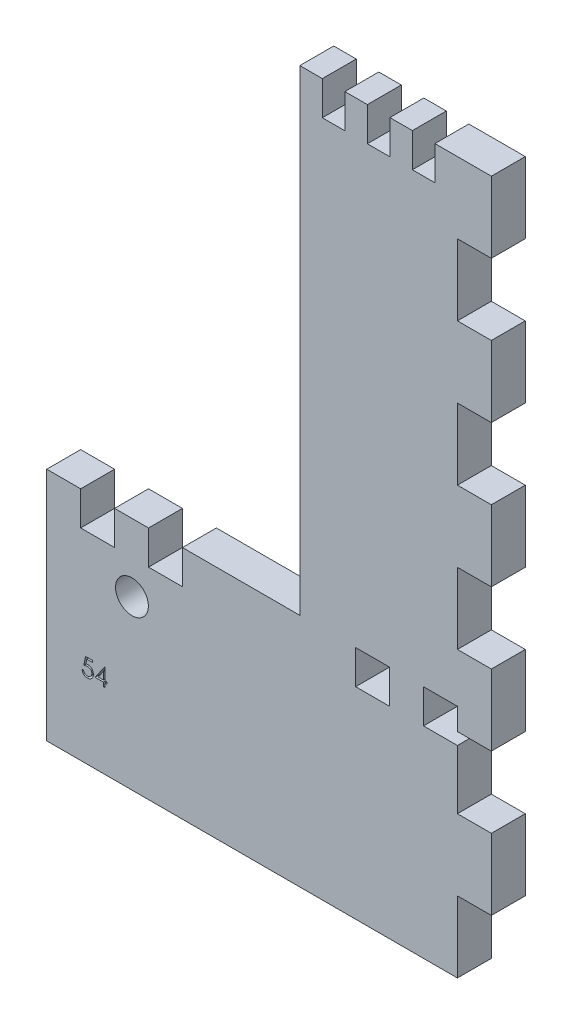
from build123d import *

# Parameters (mm, degrees)
SKETCH6_R           = 3
SKETCH6_W           = 6.2
SKETCH6_H           = 6.2
BOSS_EXTRUDE4_DEPTH = 6.2
CUT_EXTRUDE3_DEPTH  = 1


with BuildPart() as part:
    # Sketch6 → Boss-Extrude4 (new body)
    with BuildSketch(Plane.XY):
        Polygon((157.908027241, 124.653899243), (153.794027241, 124.653899243), (153.794027241, 37.653899243), (132.344027241, 37.653899243), (132.344027241, 31.453899243), (126.144027241, 31.453899243), (126.144027241, 37.653899243), (119.944027241, 37.653899243), (119.944027241, 31.453899243), (113.744027241, 31.453899243), (113.744027241, 37.653899243), (107.544027241, 37.653899243), (107.544027241, -5.346100757), (182.594027241, -5.346100757), (182.594027241, 7.653899243), (188.794027241, 7.653899243), (188.794027241, 20.653899243), (182.594027241, 20.653899243), (182.594027241, 31.453899243), (176.394027241, 31.453899243), (176.394027241, 37.653899243), (182.594027241, 37.653899243), (182.594027241, 33.653899243), (188.794027241, 33.653899243), (188.794027241, 46.653899243), (182.594027241, 46.653899243), (182.594027241, 59.653899243), (188.794027241, 59.653899243), (188.794027241, 72.653899243), (182.594027241, 72.653899243), (182.594027241, 85.653899243), (188.794027241, 85.653899243), (188.794027241, 98.653899243), (182.594027241, 98.653899243), (182.594027241, 111.653899243), (188.794027241, 111.653899243), (188.794027241, 124.653899243), (178.478027241, 124.653899243), (178.478027241, 118.453899243), (174.364027241, 118.453899243), (174.364027241, 124.653899243), (170.250027241, 124.653899243), (170.250027241, 118.453899243), (166.136027241, 118.453899243), (166.136027241, 124.653899243), (162.022027241, 124.653899243), (162.022027241, 118.453899243), (157.908027241, 118.453899243), align=None)
        with Locations((123.115137004, 25.259504391)):
            Circle(SKETCH6_R, mode=Mode.SUBTRACT)
        with Locations((167.094027241, 34.553899243)):
            Rectangle(SKETCH6_W, SKETCH6_H, mode=Mode.SUBTRACT)
    extrude(amount=BOSS_EXTRUDE4_DEPTH)

    # Sketch7 → Cut-Extrude3 (cut)
    with BuildSketch(Plane.XY.offset(6.2)):
        with BuildLine():
            Line((115.946331614, 11.576783669), (115.946331614, 11.251142644))
            Line((115.946331614, 11.251142644), (114.866373682, 11.251142644))
            Line((114.866373682, 11.251142644), (114.69528494, 10.416051498))
            add(Edge.make_bspline(
                [(114.69528494, 10.416051498), (114.728899911, 10.425331816), (114.794023603, 10.443310964), (114.890144334, 10.463273342), (114.981395832, 10.475306994), (115.040609919, 10.476950112), (115.069263305, 10.477745208)],
                knots=[0, 0, 0, 0, 0.000104595, 0.000202637, 0.000294305, 0.000380252, 0.000380252, 0.000380252, 0.000380252], degree=3))
            add(Edge.make_bspline(
                [(115.069263305, 10.477745208), (115.10471784, 10.476977823), (115.174430315, 10.475468954), (115.276428503, 10.460980204), (115.37379477, 10.43817471), (115.466325492, 10.40631538), (115.554191848, 10.365575836), (115.636585422, 10.314685176), (115.714742957, 10.255237083), (115.78726231, 10.186888393), (115.853052218, 10.111666641), (115.910897081, 10.030787715), (115.960030287, 9.945037622), (115.999546115, 9.853597069), (116.031100475, 9.75747698), (116.052102642, 9.655665995), (116.0660878, 9.549123772), (116.06765025, 9.476276054), (116.068446999, 9.439128421)],
                knots=[0, 0, 0, 0, 0.000106308, 0.000209029, 0.000308378, 0.000405929, 0.000502102, 0.000598312, 0.00069588, 0.000796219, 0.000896736, 0.000995218, 0.001094066, 0.001192613, 0.001293582, 0.001396995, 0.001504047, 0.001615439, 0.001615439, 0.001615439, 0.001615439], degree=3))
            add(Edge.make_bspline(
                [(116.068446999, 9.439128421), (116.067843681, 9.413254692), (116.066645197, 9.361856897), (116.060550479, 9.285526086), (116.048815936, 9.21081123), (116.033060929, 9.137702418), (116.012611736, 9.066338059), (115.987856666, 8.996513887), (115.957561698, 8.928664494), (115.924331807, 8.862147885), (115.886915359, 8.798467811), (115.845387713, 8.738914802), (115.801513304, 8.682595489), (115.754304332, 8.630113888), (115.703322001, 8.581814865), (115.649183746, 8.537411781), (115.592321565, 8.496153717), (115.531855738, 8.459715426), (115.469133628, 8.426184744), (115.40324946, 8.398676964), (115.335702967, 8.374083842), (115.265521973, 8.354480913), (115.192865443, 8.339120668), (115.117613611, 8.32868798), (115.040161146, 8.321089354), (114.987660242, 8.320613688), (114.961140308, 8.320373413)],
                knots=[0, 0, 0, 0, 7.7636e-05, 0.000154223, 0.000229512, 0.000304362, 0.000378447, 0.000452077, 0.000526407, 0.000601214, 0.00067506, 0.000747747, 0.00081887, 0.000889121, 0.000959302, 0.001029336, 0.001099058, 0.00116985, 0.001240974, 0.00131221, 0.00138383, 0.001456517, 0.001530612, 0.001606437, 0.001684346, 0.001763871, 0.001763871, 0.001763871, 0.001763871], degree=3))
            add(Edge.make_bspline(
                [(114.961140308, 8.320373413), (114.929504444, 8.321000102), (114.867264619, 8.322233038), (114.776078105, 8.335131235), (114.688344141, 8.353604216), (114.604768978, 8.38139569), (114.524603617, 8.41621845), (114.448927295, 8.460229548), (114.375806341, 8.51010345), (114.308213279, 8.568959198), (114.245478804, 8.633289853), (114.189320757, 8.703101427), (114.139306727, 8.777241707), (114.096237628, 8.856070747), (114.059500137, 8.939381414), (114.030639398, 9.02748585), (114.007345461, 9.119923711), (113.997490787, 9.183562967), (113.99248546, 9.215886233)],
                knots=[0, 0, 0, 0, 9.4843e-05, 0.000186593, 0.000275792, 0.000363484, 0.000450342, 0.000537514, 0.000625728, 0.000715478, 0.000805885, 0.000894984, 0.00098389, 0.001073836, 0.001164117, 0.001256635, 0.001351658, 0.001449737, 0.001449737, 0.001449737, 0.001449737], degree=3))
            Line((113.99248546, 9.215886233), (114.277421358, 9.215886233))
            add(Edge.make_bspline(
                [(114.277421358, 9.215886233), (114.284432264, 9.185609023), (114.297907613, 9.127414543), (114.327485686, 9.045652541), (114.36364973, 8.972791531), (114.406652246, 8.907867695), (114.457951202, 8.851253818), (114.516488613, 8.800801198), (114.582118333, 8.755285188), (114.655046477, 8.717345963), (114.731984056, 8.684989308), (114.812508596, 8.663443128), (114.894427539, 8.648293032), (114.949834347, 8.646776506), (114.977676767, 8.646014439)],
                knots=[0, 0, 0, 0, 9.3172e-05, 0.000179081, 0.000260145, 0.000336703, 0.000411917, 0.000488562, 0.000568128, 0.000650923, 0.00073478, 0.000817953, 0.000900557, 0.000983994, 0.000983994, 0.000983994, 0.000983994], degree=3))
            add(Edge.make_bspline(
                [(114.977676767, 8.646014439), (115.004853355, 8.646759001), (115.058364281, 8.648225052), (115.137114611, 8.659509013), (115.213144861, 8.676887667), (115.28570482, 8.702895321), (115.356064217, 8.734504458), (115.42244328, 8.77506742), (115.486762318, 8.821749008), (115.547022125, 8.875231094), (115.602212197, 8.934167888), (115.650976678, 8.997193809), (115.691595736, 9.064428377), (115.725825963, 9.134707595), (115.751818598, 9.208801714), (115.770361488, 9.286363495), (115.781249978, 9.367584512), (115.782747834, 9.4229831), (115.783511101, 9.451212756)],
                knots=[0, 0, 0, 0, 8.15e-05, 0.000160473, 0.000238226, 0.000315066, 0.000391338, 0.000469218, 0.000547964, 0.000629516, 0.000710512, 0.000789892, 0.000868102, 0.000945761, 0.001024012, 0.00110315, 0.001184644, 0.001269321, 0.001269321, 0.001269321, 0.001269321], degree=3))
            add(Edge.make_bspline(
                [(115.783511101, 9.451212756), (115.782913767, 9.476681473), (115.781744568, 9.526532864), (115.772191837, 9.59946643), (115.755575726, 9.668475547), (115.732512635, 9.733893459), (115.70323051, 9.795781868), (115.66744707, 9.854204644), (115.624490773, 9.908391764), (115.575421703, 9.95836858), (115.521666194, 10.004492145), (115.46229937, 10.043811424), (115.39856358, 10.076889406), (115.331226729, 10.105435376), (115.258687142, 10.125937481), (115.18238134, 10.141329777), (115.101485326, 10.150233713), (115.046176202, 10.15146914), (115.017745877, 10.152104182)],
                knots=[0, 0, 0, 0, 7.6388e-05, 0.000149519, 0.000220172, 0.000288967, 0.000357247, 0.000425206, 0.000494043, 0.000564207, 0.000635056, 0.000706145, 0.000777268, 0.000850264, 0.000925136, 0.001002969, 0.001083601, 0.001168886, 0.001168886, 0.001168886, 0.001168886], degree=3))
            add(Edge.make_bspline(
                [(115.017745877, 10.152104182), (114.993136063, 10.151577503), (114.942323041, 10.150490044), (114.864378762, 10.142483151), (114.782471271, 10.129566076), (114.69691455, 10.111798552), (114.60745166, 10.088547504), (114.514271397, 10.060685064), (114.417177841, 10.027372965), (114.351756762, 10.002215885), (114.318126486, 9.989283669)],
                knots=[0, 0, 0, 0, 7.3822e-05, 0.000152423, 0.000234822, 0.000322511, 0.00041445, 0.000512043, 0.000614219, 0.000722306, 0.000722306, 0.000722306, 0.000722306], degree=3))
            Line((114.318126486, 9.989283669), (114.643767512, 11.576783669))
            Line((114.643767512, 11.576783669), (115.946331614, 11.576783669))
        make_face()
        Polygon((118.127236061, 11.658193926), (118.185113666, 11.658193926), (118.185113666, 9.460117003), (118.551459819, 9.460117003), (118.551459819, 9.134475977), (118.185113666, 9.134475977), (118.185113666, 8.401783669), (117.900177768, 8.401783669), (117.900177768, 9.134475977), (116.394088025, 9.134475977), align=None)
        Polygon((117.900177768, 9.460117003), (117.900177768, 10.839003221), (116.953783537, 9.460117003), align=None, mode=Mode.SUBTRACT)
    extrude(amount=-CUT_EXTRUDE3_DEPTH, mode=Mode.SUBTRACT)


solid = part.part
